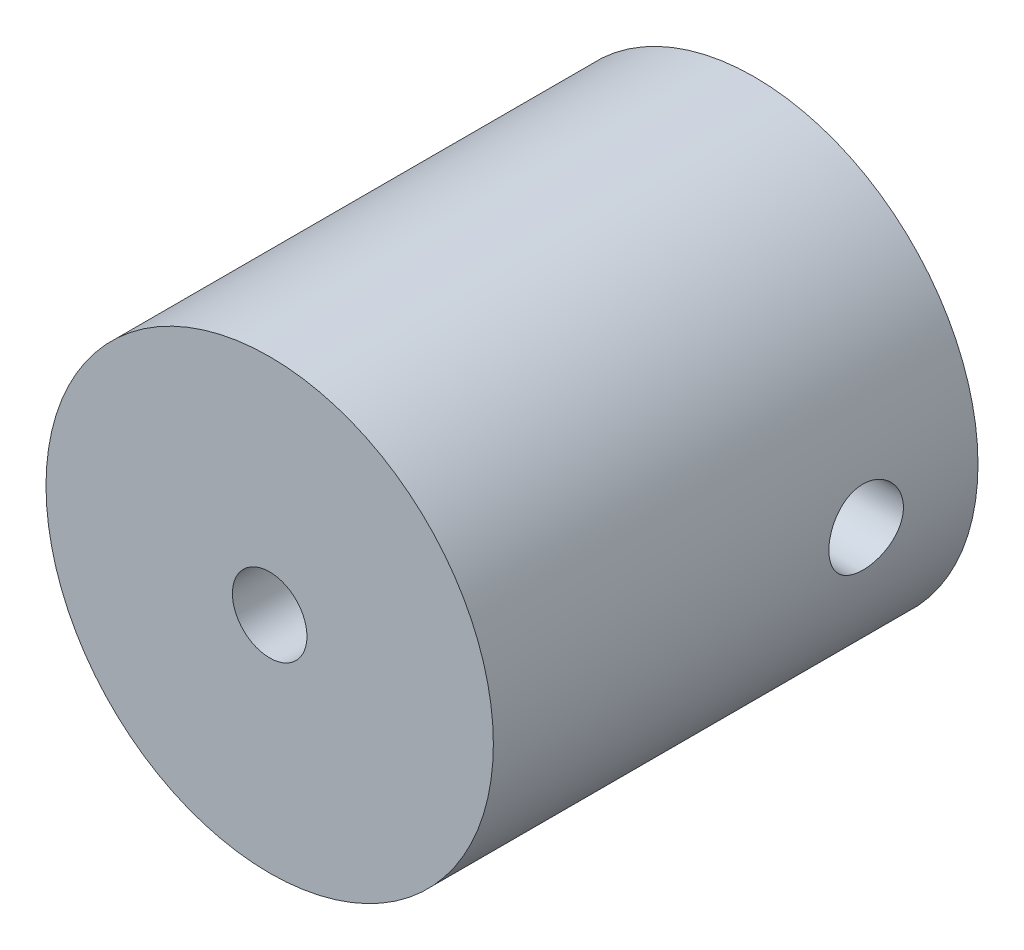
from build123d import *

# Parameters (mm, degrees)
SKETCH1_R               = 15
SKETCH1_R_2             = 2.5
BOSS_EXTRUDE1_DEPTH     = 32.5
CUT_EXTRUDE1_DEPTH      = 32.5
CUT_EXTRUDE1_DEPTH_BACK = 32.5
SKETCH2_R               = 2.5


with BuildPart() as part:
    # Sketch1 → Boss-Extrude1 (new body)
    with BuildSketch(Plane.XY):
        Circle(SKETCH1_R)
        Circle(SKETCH1_R_2, mode=Mode.SUBTRACT)
    extrude(amount=BOSS_EXTRUDE1_DEPTH)

    # Sketch2 → Cut-Extrude1 (cut, two sides: drawn at the far end of the back side and taken through both)
    with BuildSketch(Plane(origin=(0, 0, 0), x_dir=(0, 0, -1), z_dir=(1, 0, 0)).offset(-CUT_EXTRUDE1_DEPTH_BACK)):
        with Locations((-7.5, 0)):
            Circle(SKETCH2_R)
    extrude(amount=CUT_EXTRUDE1_DEPTH + CUT_EXTRUDE1_DEPTH_BACK, mode=Mode.SUBTRACT)


solid = part.part
